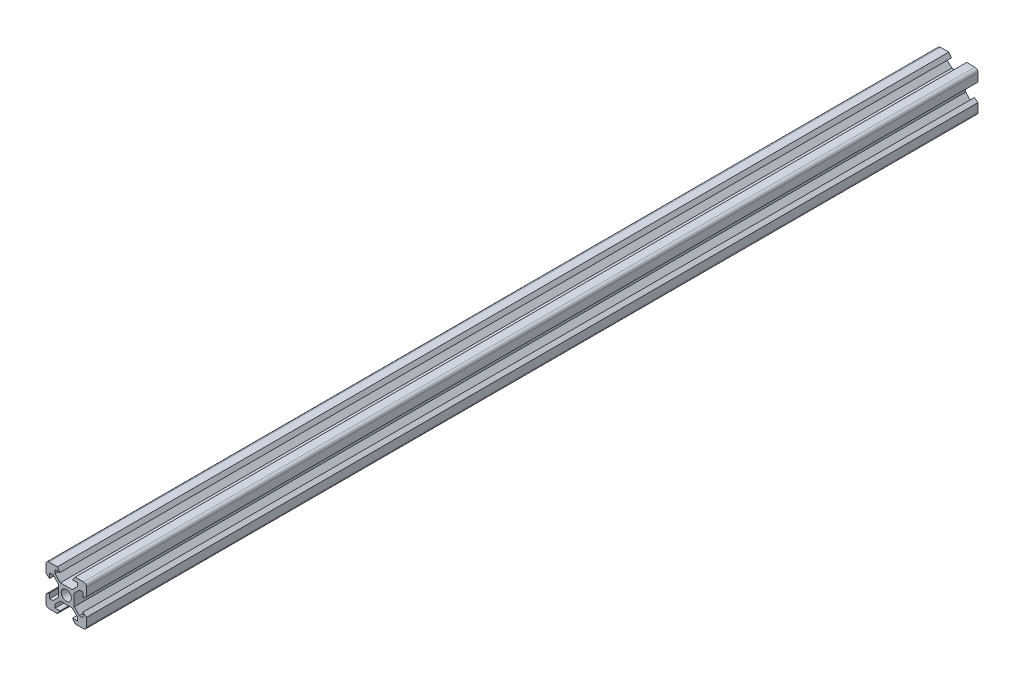
from build123d import *

# Parameters (mm, degrees)
SKETCH_1_R      = 2.5
EXTRUDE_1_DEPTH = 440


with BuildPart() as part:
    # 草图1 → 凸台-拉伸1 (new body)
    with BuildSketch(Plane.XY):
        with BuildLine():
            Line((14.8, 34.821428571), (18.9, 34.821428571))
            Line((18.9, 34.821428571), (20.2, 33.021428571))
            Line((20.2, 33.021428571), (17.8, 33.021428571))
            Line((17.8, 33.021428571), (17.8, 31.311378065))
            Line((17.8, 31.311378065), (20.389949494, 28.721428571))
            Line((20.389949494, 28.721428571), (26.210050506, 28.721428571))
            Line((26.210050506, 28.721428571), (28.8, 31.311378065))
            Line((28.8, 31.311378065), (28.8, 33.021428571))
            Line((28.8, 33.021428571), (26.4, 33.021428571))
            Line((26.4, 33.021428571), (27.7, 34.821428571))
            Line((27.7, 34.821428571), (31.8, 34.821428571))
            ThreePointArc((31.8, 34.821428571), (32.860660172, 34.382088743), (33.3, 33.321428571))
            Line((33.3, 33.321428571), (33.3, 29.221428571))
            Line((33.3, 29.221428571), (31.5, 27.921428571))
            Line((31.5, 27.921428571), (31.5, 30.321428571))
            Line((31.5, 30.321428571), (29.789949494, 30.321428571))
            Line((29.789949494, 30.321428571), (27.2, 27.731479078))
            Line((27.2, 27.731479078), (27.2, 21.911378065))
            Line((27.2, 21.911378065), (29.789949494, 19.321428571))
            Line((29.789949494, 19.321428571), (31.5, 19.321428571))
            Line((31.5, 19.321428571), (31.5, 21.721428571))
            Line((31.5, 21.721428571), (33.3, 20.421428571))
            Line((33.3, 20.421428571), (33.3, 16.321428571))
            ThreePointArc((33.3, 16.321428571), (32.860660172, 15.2607684), (31.8, 14.821428571))
            Line((31.8, 14.821428571), (27.7, 14.821428571))
            Line((27.7, 14.821428571), (26.4, 16.621428571))
            Line((26.4, 16.621428571), (28.8, 16.621428571))
            Line((28.8, 16.621428571), (28.8, 18.331479078))
            Line((28.8, 18.331479078), (26.210050506, 20.921428571))
            Line((26.210050506, 20.921428571), (20.389949494, 20.921428571))
            Line((20.389949494, 20.921428571), (17.8, 18.331479078))
            Line((17.8, 18.331479078), (17.8, 16.621428571))
            Line((17.8, 16.621428571), (20.2, 16.621428571))
            Line((20.2, 16.621428571), (18.9, 14.821428571))
            Line((18.9, 14.821428571), (14.8, 14.821428571))
            ThreePointArc((14.8, 14.821428571), (13.739339828, 15.2607684), (13.3, 16.321428571))
            Line((13.3, 16.321428571), (13.3, 20.421428571))
            Line((13.3, 20.421428571), (15.1, 21.721428571))
            Line((15.1, 21.721428571), (15.1, 19.321428571))
            Line((15.1, 19.321428571), (16.810050506, 19.321428571))
            Line((16.810050506, 19.321428571), (19.4, 21.911378065))
            Line((19.4, 21.911378065), (19.4, 27.731479078))
            Line((19.4, 27.731479078), (16.810050506, 30.321428571))
            Line((16.810050506, 30.321428571), (15.1, 30.321428571))
            Line((15.1, 30.321428571), (15.1, 27.921428571))
            Line((15.1, 27.921428571), (13.3, 29.221428571))
            Line((13.3, 29.221428571), (13.3, 33.321428571))
            ThreePointArc((13.3, 33.321428571), (13.739339828, 34.382088743), (14.8, 34.821428571))
        make_face()
        with Locations((23.3, 24.821428571)):
            Circle(SKETCH_1_R, mode=Mode.SUBTRACT)
    extrude(amount=EXTRUDE_1_DEPTH)


solid = part.part
